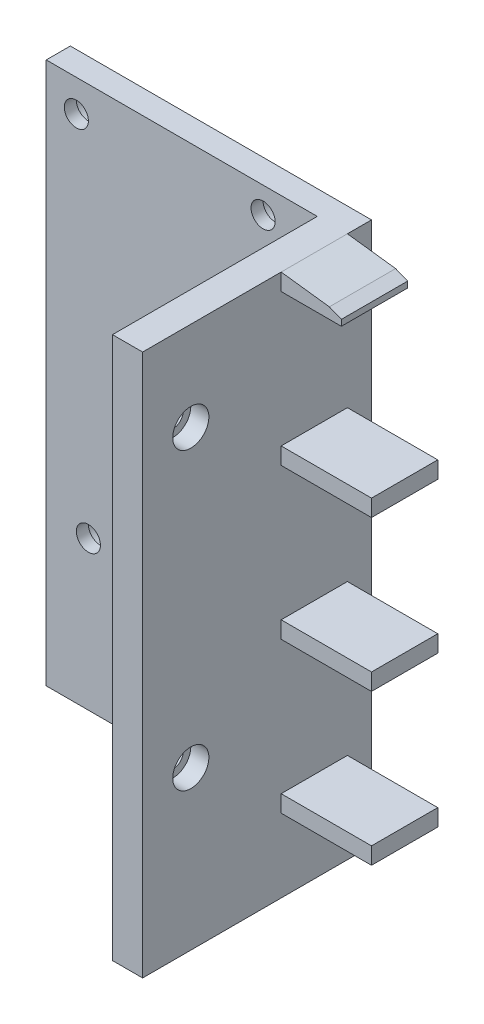
from build123d import *

# Parameters (mm, degrees)
EXTRUDE_1_DEPTH     = 38
EXTRUDE_1_2_DEPTH   = 38
EXTRUDE_7_DEPTH     = 38
SKETCH_13_W         = 45
SKETCH_13_H         = 4
EXTRUDE_9_DEPTH     = 90
SKETCH_1_4_W        = 5
SKETCH_1_4_H        = 2.2
EXTRUDE_10_DEPTH    = 38
SKETCH_11_R         = 1.75
CUT_EXTRUDE_2_DEPTH = 38
CUT_EXTRUDE_START   = -2
SKETCH_11_3_R       = 3
SKETCH_11_3_R_2     = 1.75
CUT_EXTRUDE_3_DEPTH = 38
SKETCH_15_R         = 2
CUT_EXTRUDE_4_DEPTH = 38
SKETCH_15_3_R       = 3
SKETCH_15_3_R_2     = 2
CUT_EXTRUDE_5_DEPTH = 38
SKETCH_17_W         = 15
SKETCH_17_H         = 2.8
EXTRUDE_12_DEPTH    = 23
SKETCH_18_W         = 2
SKETCH_18_H         = 1
CUT_EXTRUDE_6_DEPTH = 40
SKETCH_17_2_W       = 15
SKETCH_17_2_H       = 2.8
SKETCH_17_2_W_2     = 10
SKETCH_17_2_H_2     = 3.8
CUT_EXTRUDE_7_DEPTH = 23
SKETCH_20_W         = 15
SKETCH_20_H         = 4
CUT_EXTRUDE_8_DEPTH = 89
SKETCH_17_4_W       = 5
SKETCH_17_4_H       = 10
EXTRUDE_13_DEPTH    = 38


with BuildPart() as part:
    # 스케치1 → 보스-돌출1 (new body)
    with BuildSketch(Plane.XY):
        Polygon((15, -3.8), (15, -1.8), (13, -1), (13, -3.8), align=None)
    extrude(amount=EXTRUDE_1_DEPTH)



with BuildPart() as body_2:
    # 스케치1 → Extrude 1 2 (new body)
    with BuildSketch(Plane.XY):
        Polygon((5, -75), (5, -52.8), (20, -52.8), (20, -50), (5, -50), (5, -27.8), (20, -27.8), (20, -25), (5, -25), (5, 0), (0, 0), (0, -77.8), (20, -77.8), (20, -75), align=None)
    extrude(amount=EXTRUDE_1_2_DEPTH)


with BuildPart() as part_1:
    add(part.part)

    add(body_2.part)  # 보스-돌출7 merges body 2
    # 스케치1<3> → 보스-돌출7 (add)
    with BuildSketch(Plane.XY):
        Polygon((13, -2.8), (13, -1), (5, 0), (5, -0.74611229), (5, -2.8), align=None)
    extrude(amount=EXTRUDE_7_DEPTH)

    # 스케치13 → 보스-돌출9 (add)
    with BuildSketch(Plane(origin=(0, 0, 0), x_dir=(1, 0, 0), z_dir=(0, 1, 0))):
        with Locations((-22.5, -2)):
            Rectangle(SKETCH_13_W, SKETCH_13_H)
    extrude(amount=-EXTRUDE_9_DEPTH)

    # 스케치1<4> → 보스-돌출10 (add)
    with BuildSketch(Plane.XY):
        with Locations((2.5, -78.9)):
            Rectangle(SKETCH_1_4_W, SKETCH_1_4_H)
    extrude(amount=EXTRUDE_10_DEPTH)

    # 스케치11 → 컷-돌출2 (cut)
    with BuildSketch(Plane.ZY):
        with Locations((30, -63.769774624)):
            Circle(SKETCH_11_R)
        with Locations((30, -14.819294268)):
            Circle(SKETCH_11_R)
    extrude(amount=-CUT_EXTRUDE_2_DEPTH, mode=Mode.SUBTRACT)

    # 스케치11<3> → 컷-돌출3 (cut)
    with BuildSketch(Plane.ZY.offset(CUT_EXTRUDE_START)):
        with Locations((30, -63.769774624)):
            Circle(SKETCH_11_3_R)
        with Locations((30, -63.769774624)):
            Circle(SKETCH_11_3_R_2, mode=Mode.SUBTRACT)
        with Locations((30, -14.819294268)):
            Circle(SKETCH_11_3_R)
        with Locations((30, -14.819294268)):
            Circle(SKETCH_11_3_R_2, mode=Mode.SUBTRACT)
    extrude(amount=-CUT_EXTRUDE_3_DEPTH, mode=Mode.SUBTRACT)

    # 스케치15 → 컷-돌출4 (cut)
    with BuildSketch(Plane.XY.offset(4)):
        with Locations((-40, -5.284222689)):
            Circle(SKETCH_15_R)
        with Locations((-9, -4.284222689)):
            Circle(SKETCH_15_R)
        with Locations((-9, -65.284222689)):
            Circle(SKETCH_15_R)
        with Locations((-38, -65.284222689)):
            Circle(SKETCH_15_R)
    extrude(amount=-CUT_EXTRUDE_4_DEPTH, mode=Mode.SUBTRACT)

    # 스케치15<3> → 컷-돌출5 (cut)
    with BuildSketch(Plane.XY.offset(4).offset(CUT_EXTRUDE_START)):
        with Locations((-40, -5.284222689)):
            Circle(SKETCH_15_3_R)
        with Locations((-40, -5.284222689)):
            Circle(SKETCH_15_3_R_2, mode=Mode.SUBTRACT)
        with Locations((-38, -65.284222689)):
            Circle(SKETCH_15_3_R)
        with Locations((-38, -65.284222689)):
            Circle(SKETCH_15_3_R_2, mode=Mode.SUBTRACT)
        with Locations((-9, -65.284222689)):
            Circle(SKETCH_15_3_R)
        with Locations((-9, -65.284222689)):
            Circle(SKETCH_15_3_R_2, mode=Mode.SUBTRACT)
        with Locations((-9, -4.284222689)):
            Circle(SKETCH_15_3_R)
        with Locations((-9, -4.284222689)):
            Circle(SKETCH_15_3_R_2, mode=Mode.SUBTRACT)
    extrude(amount=-CUT_EXTRUDE_5_DEPTH, mode=Mode.SUBTRACT)

    # 스케치17 → 보스-돌출12 (add)
    with BuildSketch(Plane.XY.offset(38)):
        with Locations((12.5, -26.4)):
            Rectangle(SKETCH_17_W, SKETCH_17_H)
        with Locations((12.5, -51.4)):
            Rectangle(SKETCH_17_W, SKETCH_17_H)
        with Locations((12.5, -76.4)):
            Rectangle(SKETCH_17_W, SKETCH_17_H)
    extrude(amount=-EXTRUDE_12_DEPTH)

    # 스케치18 → 컷-돌출6 (cut)
    with BuildSketch(Plane.XY.offset(38)):
        with Locations((14, -3.3)):
            Rectangle(SKETCH_18_W, SKETCH_18_H)
    extrude(amount=-CUT_EXTRUDE_6_DEPTH, mode=Mode.SUBTRACT)

    # 스케치17<2> → 컷-돌출7 (cut)
    with BuildSketch(Plane.XY.offset(38)):
        with Locations((12.5, -76.4)):
            Rectangle(SKETCH_17_2_W, SKETCH_17_2_H)
        with Locations((12.5, -51.4)):
            Rectangle(SKETCH_17_2_W, SKETCH_17_2_H)
        with Locations((12.5, -26.4)):
            Rectangle(SKETCH_17_2_W, SKETCH_17_2_H)
        with Locations((10, -1.9)):
            Rectangle(SKETCH_17_2_W_2, SKETCH_17_2_H_2)
    extrude(amount=-CUT_EXTRUDE_7_DEPTH, mode=Mode.SUBTRACT)

    # 스케치20 → 컷-돌출8 (cut)
    with BuildSketch(Plane(origin=(0, 0, 0), x_dir=(1, 0, 0), z_dir=(0, 1, 0))):
        with Locations((12.5, -2)):
            Rectangle(SKETCH_20_W, SKETCH_20_H)
    extrude(amount=-CUT_EXTRUDE_8_DEPTH, mode=Mode.SUBTRACT)

    # 스케치17<4> → 보스-돌출13 (add)
    with BuildSketch(Plane.XY.offset(38)):
        with Locations((2.5, -85)):
            Rectangle(SKETCH_17_4_W, SKETCH_17_4_H)
    extrude(amount=-EXTRUDE_13_DEPTH)


solid = part_1.part
